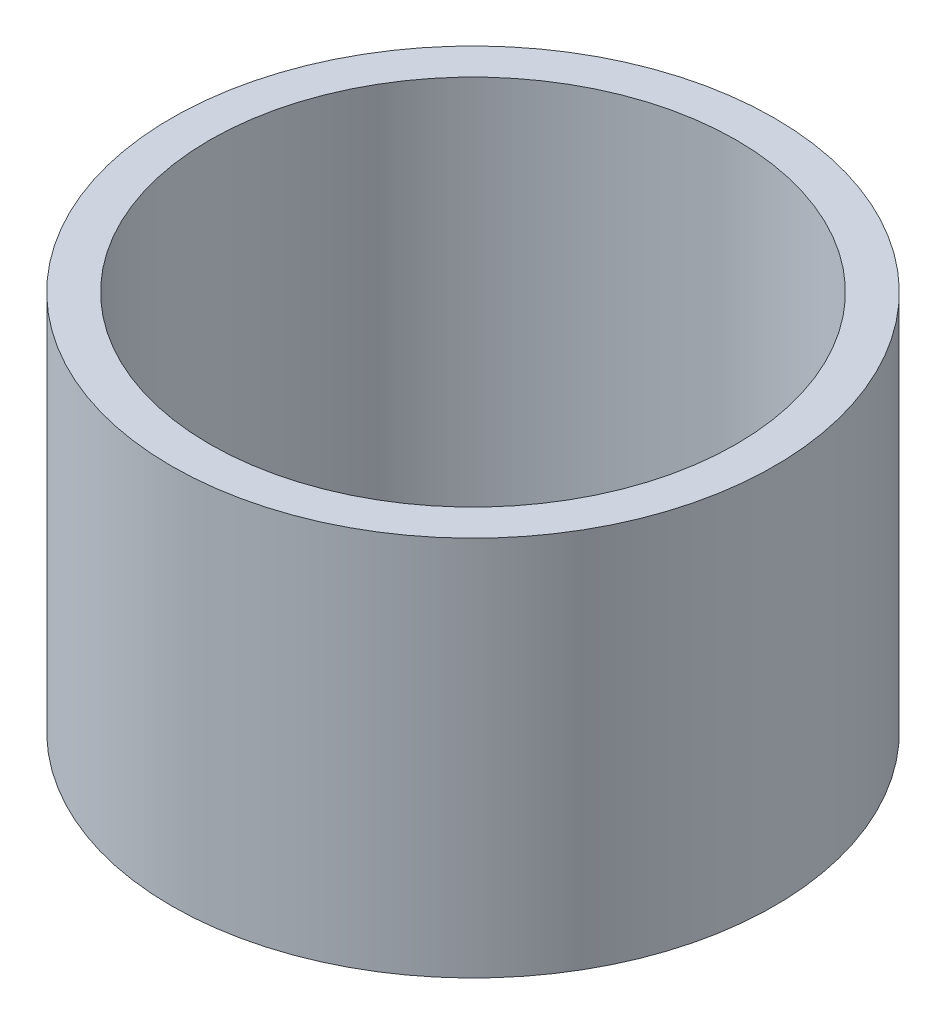
from build123d import *

# Parameters (mm, degrees)
SKETCH1_R           = 50.2539
SKETCH1_R_2         = 43.9039
BOSS_EXTRUDE1_DEPTH = 63.5


with BuildPart() as part:
    # Sketch1 → Boss-Extrude1 (new body)
    with BuildSketch(Plane(origin=(0, 0, 0), x_dir=(1, 0, 0), z_dir=(0, 1, 0))):
        Circle(SKETCH1_R)
        Circle(SKETCH1_R_2, mode=Mode.SUBTRACT)
    extrude(amount=BOSS_EXTRUDE1_DEPTH)


solid = part.part
